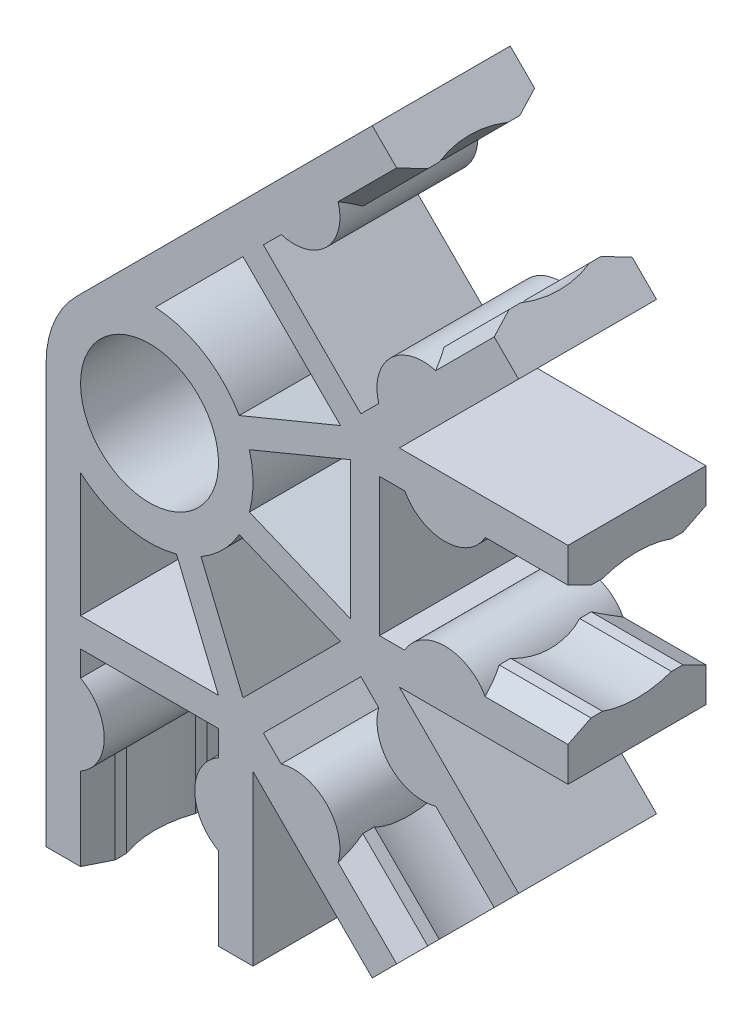
from build123d import *

# Parameters (mm, degrees)
EXTRUDE_1_DEPTH          = 6
EXTRUDE_2_REACH          = 25.907
PATTERN_CIRCULAR_1_COUNT = 4
PATTERN_CIRCULAR_1_ANGLE = 135
SKETCH_4_R               = 3
CUT_EXTRUDE_1_DEPTH      = 27.42877236


with BuildPart() as part:
    # 草图1 → 凸台-拉伸1 (new body)
    with BuildSketch(Plane.XY):
        with BuildLine():
            Line((-4.5, 0), (-4.5, -18.2))
            Line((-4.5, -18.2), (-3, -18.2))
            Line((-3, -18.2), (-3, -14.6))
            ThreePointArc((-3, -14.6), (-1.968245837, -12.85), (-3, -11.1))
            Line((-3, -11.1), (-3, -10))
            Line((-3, -10), (3, -10))
            Line((3, -10), (3, -11.1))
            ThreePointArc((3, -11.1), (1.968245837, -12.85), (3, -14.6))
            Line((3, -14.6), (3, -18.2))
            Line((3, -18.2), (4.5, -18.2))
            Line((4.5, -18.2), (4.5, 0))
            ThreePointArc((4.5, 0), (0, 4.5), (-4.5, 0))
        make_face()
    extrude_1 = extrude(amount=EXTRUDE_1_DEPTH)

    # 草图3 → 凸台-拉伸2 (add, up to next)
    with BuildSketch(Plane.XZ.offset(18.2), mode=Mode.PRIVATE) as extrude_2_sk1:
        with BuildLine():
            Line((-3, 6), (-3, 0))
            Line((-3, 0), (-2.5, 1))
            Line((-2.5, 1), (-2.5, 1.5))
            ThreePointArc((-2.5, 1.5), (-2.757359313, 3), (-2.5, 4.5))
            Line((-2.5, 4.5), (-2.5, 5))
            Line((-2.5, 5), (-3, 6))
        make_face()
    extrude_2_tool1 = extrude(extrude_2_sk1.sketch, amount=-EXTRUDE_2_REACH, mode=Mode.PRIVATE) - part.part
    # 草图3 → 凸台-拉伸2 (add, up to next)
    with BuildSketch(Plane.XZ.offset(18.2), mode=Mode.PRIVATE) as extrude_2_sk2:
        with BuildLine():
            Line((3, 0), (2.5, 1))
            Line((2.5, 1), (2.5, 1.5))
            ThreePointArc((2.5, 1.5), (2.757359313, 3), (2.5, 4.5))
            Line((2.5, 4.5), (2.5, 5))
            Line((2.5, 5), (3, 6))
            Line((3, 6), (3, 0))
        make_face()
    extrude_2_tool2 = extrude(extrude_2_sk2.sketch, amount=-EXTRUDE_2_REACH, mode=Mode.PRIVATE) - part.part
    extrude_2_1 = extrude_2_tool1.solids().sort_by_distance((-2.809362, -18.2, 3))[0]
    add(extrude_2_1)
    extrude_2_2 = extrude_2_tool2.solids().sort_by_distance((2.809362, -18.2, 3))[0]
    add(extrude_2_2)
    extrude_2 = extrude_2_1 + extrude_2_2  # 凸台-拉伸2 as one shape, for the pattern or mirror that repeats it

    # 阵列(圆周)1: 凸台-拉伸1, 凸台-拉伸2 ×4 about axis
    pattern_circular_1_axis = Axis((0, 0, 0), (0, 0, 1))
    add([extrude_1.rotate(pattern_circular_1_axis, i * PATTERN_CIRCULAR_1_ANGLE / (PATTERN_CIRCULAR_1_COUNT - 1)) for i in range(1, PATTERN_CIRCULAR_1_COUNT)])
    add([extrude_2.rotate(pattern_circular_1_axis, i * PATTERN_CIRCULAR_1_ANGLE / (PATTERN_CIRCULAR_1_COUNT - 1)) for i in range(1, PATTERN_CIRCULAR_1_COUNT)])

    # 草图4 → 切除-拉伸1 (cut, through all)
    with BuildSketch(Plane(origin=(0, 0, 0), x_dir=(-1, 0, 0), z_dir=(0, 0, -1))):
        Circle(SKETCH_4_R)
        with BuildLine():
            Line((3, -8.75), (3, -3.354101966))
            ThreePointArc((3, -3.354101966), (1.038095674, -4.378625055), (-1.174936357, -4.343906601))
            Line((-1.174936357, -4.343906601), (-3, -8.75))
            Line((-3, -8.75), (3, -8.75))
        make_face()
        with BuildLine():
            Line((-8.308504679, -4.065863992), (-4.065863992, -8.308504679))
            Line((-4.065863992, -8.308504679), (-2.240800349, -3.90241128))
            ThreePointArc((-2.240800349, -3.90241128), (-3.181980515, -3.181980515), (-3.90241128, -2.240800349))
            Line((-3.90241128, -2.240800349), (-8.308504679, -4.065863992))
        make_face()
        with BuildLine():
            Line((-8.75, -3), (-4.343906601, -1.174936357))
            ThreePointArc((-4.343906601, -1.174936357), (-4.5, 0), (-4.343906601, 1.174936357))
            Line((-4.343906601, 1.174936357), (-8.75, 3))
            Line((-8.75, 3), (-8.75, -3))
        make_face()
        with BuildLine():
            Line((-4.065863992, 8.308504679), (-0.250387902, 4.493028589))
            ThreePointArc((-0.250387902, 4.493028589), (-2.362110978, 3.830199959), (-3.90241128, 2.240800349))
            Line((-3.90241128, 2.240800349), (-8.308504679, 4.065863992))
            Line((-8.308504679, 4.065863992), (-4.065863992, 8.308504679))
        make_face()
    extrude(amount=-CUT_EXTRUDE_1_DEPTH, mode=Mode.SUBTRACT)


solid = part.part
